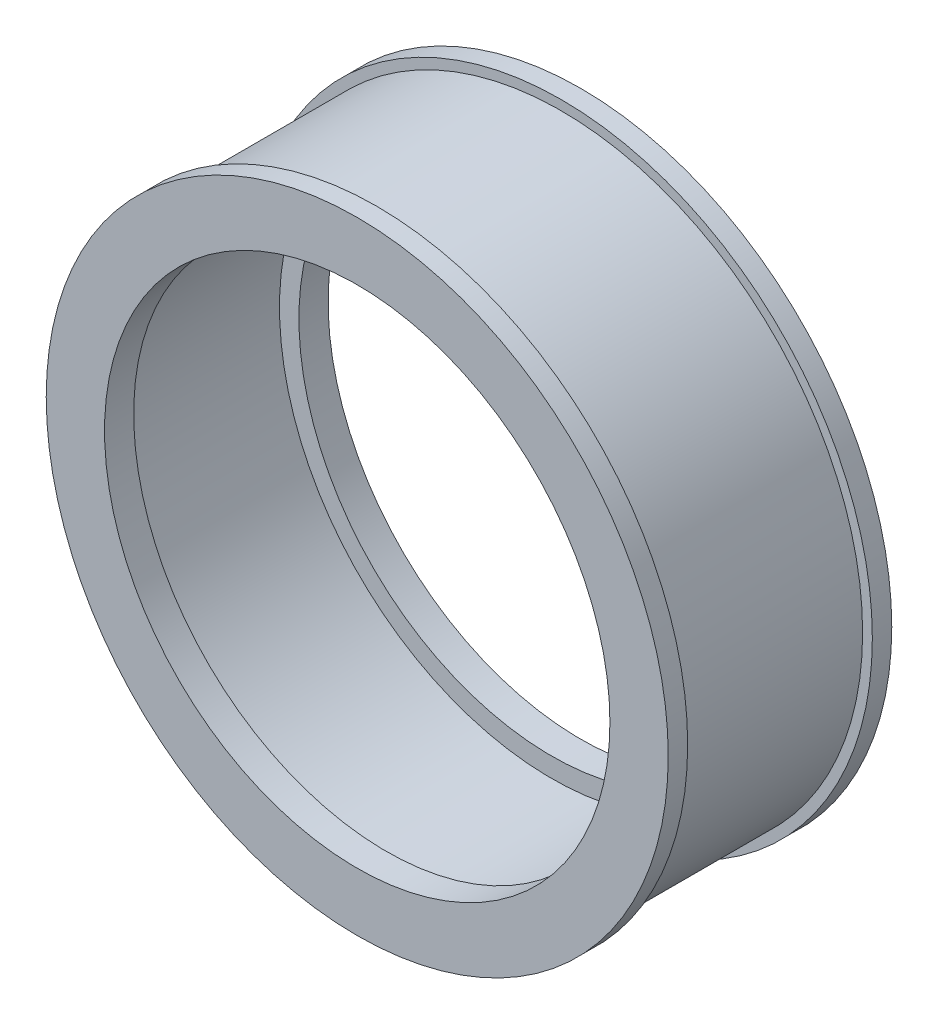
from build123d import *


with BuildPart() as part:
    # Sketch1 → Revolve1 (revolve)
    with BuildSketch(Plane(origin=(0, 0, 0), x_dir=(1, 0, 0), z_dir=(0, 1, 0))):
        Polygon((26, 11.5), (32, 11.5), (32, 9.5), (31, 9.5), (31, -9.5), (32, -9.5), (32, -11.5), (26, -11.5), (26, -8.5), (28, -8.5), (28, 8.5), (26, 8.5), align=None)
    revolve(axis=Axis((0, 0, 0), (0, 0, -1)))


solid = part.part
